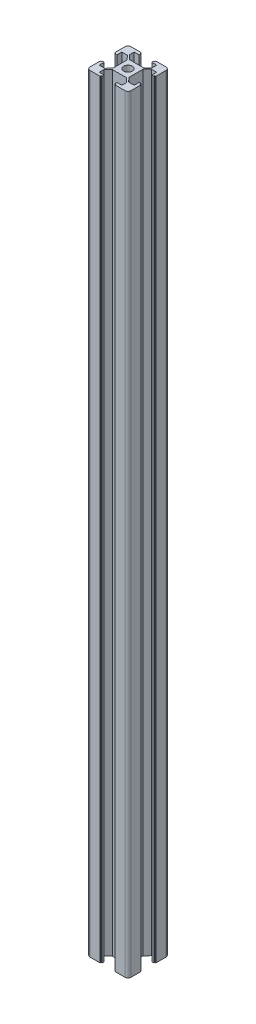
from build123d import *

# Parameters (mm, degrees)
SKETCH1_R             = 2
BOSS_EXTRUDE1_DEPTH   = 374
M5_TAPPED_HOLE1_D     = 4.2
M5_TAPPED_HOLE1_DEPTH = 10
M5_TAPPED_HOLE1_TIP   = 1.2618073
M5_TAPPED_HOLE2_D     = 4.2
M5_TAPPED_HOLE2_DEPTH = 11.6
M5_TAPPED_HOLE2_TIP   = 1.2618073


with BuildPart() as part:
    # Sketch1 → Boss-Extrude1 (new body)
    with BuildSketch(Plane(origin=(0, 0, 0), x_dir=(1, 0, 0), z_dir=(0, 1, 0))):
        with BuildLine():
            Line((1.5, 20), (6.4, 20))
            Line((6.4, 20), (6.4, 19.5))
            Line((6.4, 19.5), (6.9, 19.5))
            Line((6.9, 19.5), (6.9, 18.5))
            Line((6.9, 18.5), (4.5, 18.5))
            Line((4.5, 18.5), (4.5, 16.237261743))
            Line((4.5, 16.237261743), (6.5, 14.165503925))
            Line((6.5, 14.165503925), (13.5, 14.165503925))
            Line((13.5, 14.165503925), (15.5, 16.237261743))
            Line((15.5, 16.237261743), (15.5, 18.5))
            Line((15.5, 18.5), (13.1, 18.5))
            Line((13.1, 18.5), (13.1, 19.5))
            Line((13.1, 19.5), (13.6, 19.5))
            Line((13.6, 19.5), (13.6, 20))
            Line((13.6, 20), (18.5, 20))
            ThreePointArc((18.5, 20), (19.560660172, 19.560660172), (20, 18.5))
            Line((20, 18.5), (20, 13.6))
            Line((20, 13.6), (19.5, 13.6))
            Line((19.5, 13.6), (19.5, 13.1))
            Line((19.5, 13.1), (18.5, 13.1))
            Line((18.5, 13.1), (18.5, 15.5))
            Line((18.5, 15.5), (15.8307276, 15.5))
            Line((15.8307276, 15.5), (13.9, 13.5))
            Line((13.9, 13.5), (13.9, 6.5))
            Line((13.9, 6.5), (15.8307276, 4.5))
            Line((15.8307276, 4.5), (18.5, 4.5))
            Line((18.5, 4.5), (18.5, 6.9))
            Line((18.5, 6.9), (19.5, 6.9))
            Line((19.5, 6.9), (19.5, 6.4))
            Line((19.5, 6.4), (20, 6.4))
            Line((20, 6.4), (20, 1.5))
            ThreePointArc((20, 1.5), (19.560660172, 0.439339828), (18.5, 0))
            Line((18.5, 0), (13.6, 0))
            Line((13.6, 0), (13.6, 0.5))
            Line((13.6, 0.5), (13.1, 0.5))
            Line((13.1, 0.5), (13.1, 1.5))
            Line((13.1, 1.5), (15.5, 1.5))
            Line((15.5, 1.5), (15.5, 3.762738257))
            Line((15.5, 3.762738257), (13.5, 5.834496075))
            Line((13.5, 5.834496075), (6.5, 5.834496075))
            Line((6.5, 5.834496075), (4.5, 3.762738257))
            Line((4.5, 3.762738257), (4.5, 1.5))
            Line((4.5, 1.5), (6.9, 1.5))
            Line((6.9, 1.5), (6.9, 0.5))
            Line((6.9, 0.5), (6.4, 0.5))
            Line((6.4, 0.5), (6.4, 0))
            Line((6.4, 0), (1.5, 0))
            ThreePointArc((1.5, 0), (0.439339828, 0.439339828), (0, 1.5))
            Line((0, 1.5), (0, 6.4))
            Line((0, 6.4), (0.5, 6.4))
            Line((0.5, 6.4), (0.5, 6.9))
            Line((0.5, 6.9), (1.5, 6.9))
            Line((1.5, 6.9), (1.5, 4.5))
            Line((1.5, 4.5), (4.1692724, 4.5))
            Line((4.1692724, 4.5), (6.1, 6.5))
            Line((6.1, 6.5), (6.1, 13.5))
            Line((6.1, 13.5), (4.1692724, 15.5))
            Line((4.1692724, 15.5), (1.5, 15.5))
            Line((1.5, 15.5), (1.5, 13.1))
            Line((1.5, 13.1), (0.5, 13.1))
            Line((0.5, 13.1), (0.5, 13.6))
            Line((0.5, 13.6), (0, 13.6))
            Line((0, 13.6), (0, 18.5))
            ThreePointArc((0, 18.5), (0.439339828, 19.560660172), (1.5, 20))
        make_face()
        with Locations((10, 10)):
            Circle(SKETCH1_R, mode=Mode.SUBTRACT)
    extrude(amount=BOSS_EXTRUDE1_DEPTH)

    # M5 Tapped Hole1
    with Locations(Plane(origin=(0, 374, 0), x_dir=(1, 0, 0), z_dir=(0, 1, 0))):
        with Locations((10, 10)):
            Hole(M5_TAPPED_HOLE1_D / 2, depth=M5_TAPPED_HOLE1_DEPTH)
            with Locations((0, 0, -(M5_TAPPED_HOLE1_DEPTH + M5_TAPPED_HOLE1_TIP / 2))):  # 118° drill point
                Cone(0, M5_TAPPED_HOLE1_D / 2, M5_TAPPED_HOLE1_TIP, mode=Mode.SUBTRACT)

    # M5 Tapped Hole2
    with Locations(Plane(origin=(0, 0, 0), x_dir=(-1, 0, 0), z_dir=(0, -1, 0))):
        with Locations((-10, 10)):
            Hole(M5_TAPPED_HOLE2_D / 2, depth=M5_TAPPED_HOLE2_DEPTH)
            with Locations((0, 0, -(M5_TAPPED_HOLE2_DEPTH + M5_TAPPED_HOLE2_TIP / 2))):  # 118° drill point
                Cone(0, M5_TAPPED_HOLE2_D / 2, M5_TAPPED_HOLE2_TIP, mode=Mode.SUBTRACT)


solid = part.part
